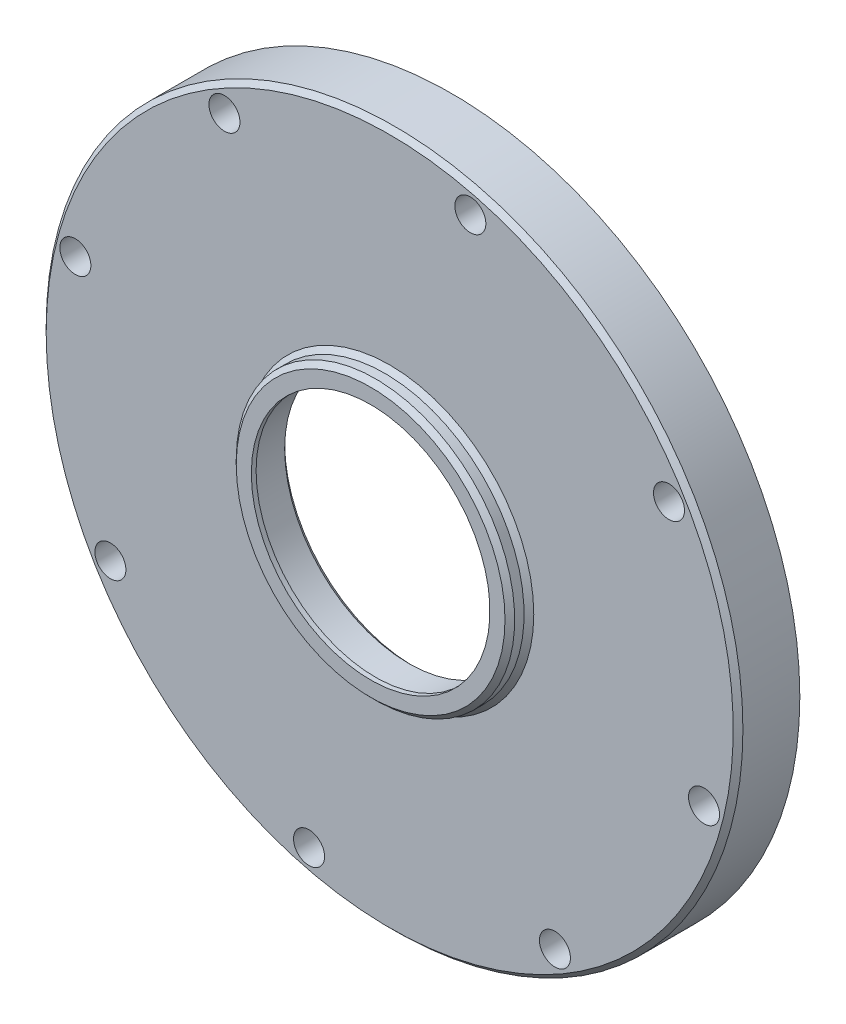
from build123d import *

# Parameters (mm, degrees)
SKETCH2_R               = 3.25
CUT_EXTRUDE1_DEPTH      = 9.138277453
CUT_EXTRUDE1_DEPTH_BACK = 9.799222547


with BuildPart() as part:
    # Sketch1 → Revolve1 (revolve)
    with BuildSketch(Plane(origin=(0, 0, 0), x_dir=(0, 0, -1), z_dir=(1, 0, 0))):
        Polygon((0.861722547, -29.175), (0.048922547, -29.175), (-0.967077453, -30.191), (-0.967077453, -61.484), (0.048922547, -62.5), (8.799222547, -62.5), (8.799222547, -73), (-3.126077453, -73), (-4.142077453, -71.984), (-4.142077453, -30.191), (-5.158077453, -29.175), (-7.122277453, -29.175), (-8.138277453, -28.159), (-8.138277453, -25), (-7.138277453, -25), (-7.138277453, -26), (-0.154277453, -26), (0.861722547, -27.016), align=None)
    revolve(axis=Axis((0, 0, 0), (0, 0, 1)))

    # Sketch2 → Cut-Extrude1 (cut, two sides)
    with BuildSketch(Plane.XY) as cut_extrude1_sk:
        with Locations((-58.52440797, -34.625043996)):
            Circle(SKETCH2_R)
        with Locations((-65.866609149, 16.899402332)):
            Circle(SKETCH2_R)
        with Locations((-34.625043996, 58.52440797)):
            Circle(SKETCH2_R)
        with Locations((16.899402332, 65.866609149)):
            Circle(SKETCH2_R)
        with Locations((58.52440797, 34.625043996)):
            Circle(SKETCH2_R)
        with Locations((65.866609149, -16.899402332)):
            Circle(SKETCH2_R)
        with Locations((34.625043996, -58.52440797)):
            Circle(SKETCH2_R)
        with Locations((-16.899402332, -65.866609149)):
            Circle(SKETCH2_R)
    extrude(amount=CUT_EXTRUDE1_DEPTH, mode=Mode.SUBTRACT)
    extrude(cut_extrude1_sk.sketch, amount=-CUT_EXTRUDE1_DEPTH_BACK, mode=Mode.SUBTRACT)


solid = part.part
